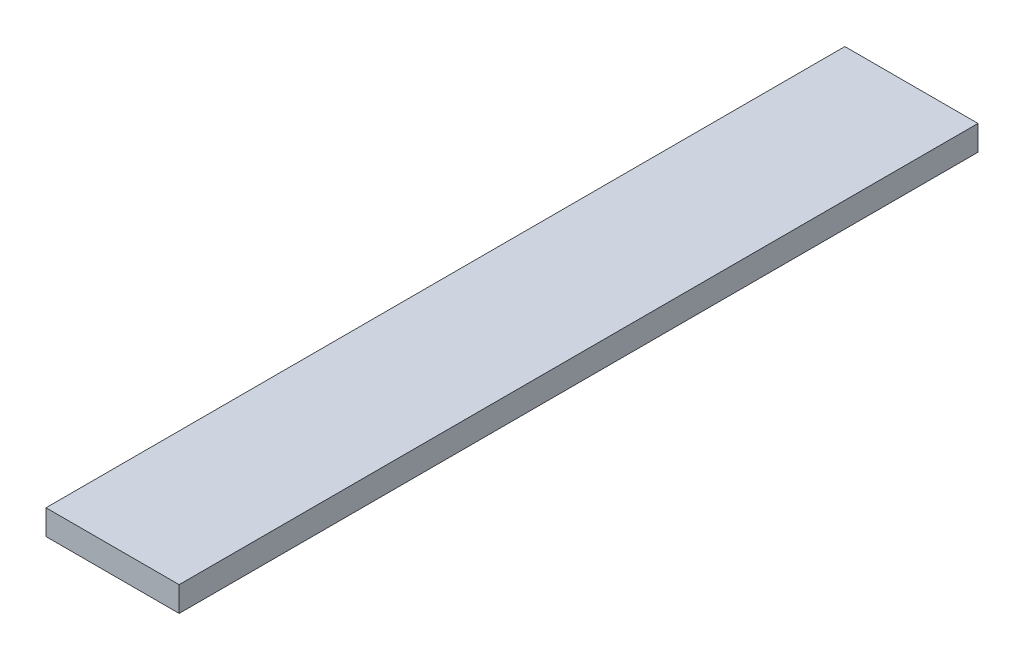
from build123d import *

# Parameters (mm, degrees)
SKETCH1_W           = 101.6
SKETCH1_H           = 609.6
BOSS_EXTRUDE1_DEPTH = 19.05


with BuildPart() as part:
    # Sketch1 → Boss-Extrude1 (new body)
    with BuildSketch(Plane(origin=(0, 0, 0), x_dir=(1, 0, 0), z_dir=(0, 1, 0))):
        Rectangle(SKETCH1_W, SKETCH1_H)
    extrude(amount=BOSS_EXTRUDE1_DEPTH)


solid = part.part
